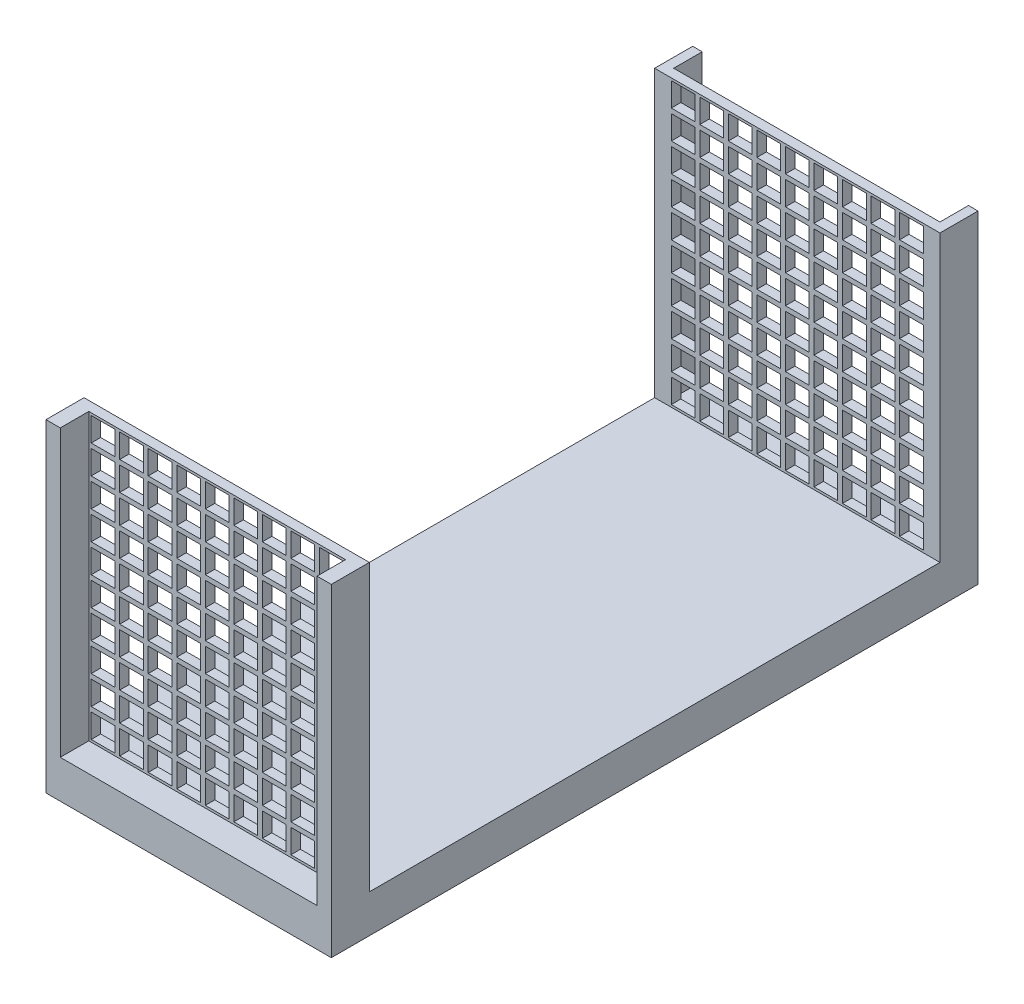
from build123d import *

# Parameters (mm, degrees)
SKETCH1_W            = 15
SKETCH1_H            = 17
BOSS_EXTRUDE1_DEPTH  = 34
CUT_EXTRUDE1_REACH   = 17
SKETCH2_W            = 30
SKETCH2_H            = 15
SKETCH3_W            = 13.5
SKETCH3_H            = 15
CUT_EXTRUDE2_DEPTH   = 1.5
SKETCH4_W            = 1.25
SKETCH4_H            = 1.25
CUT_EXTRUDE3_DEPTH   = 33.5
LPATTERN1_COUNT      = 9
LPATTERN1_PITCH      = 1.5
LPATTERN1_COUNT_DIR2 = 10
LPATTERN1_PITCH_DIR2 = 1.5
SKETCH5_W            = 14
SKETCH5_H            = 15
CUT_EXTRUDE4_DEPTH   = 1.5


with BuildPart() as part:
    # Sketch1 → Boss-Extrude1 (new body)
    with BuildSketch(Plane.XY):
        Rectangle(SKETCH1_W, SKETCH1_H)
    extrude(amount=BOSS_EXTRUDE1_DEPTH)

    # Sketch2 → Cut-Extrude1 (cut, up to next)
    with BuildSketch(Plane(origin=(7.5, 0, 0), x_dir=(0, 0, -1), z_dir=(1, 0, 0)), mode=Mode.PRIVATE) as cut_extrude1_sk1:
        with Locations((-17, 1)):
            Rectangle(SKETCH2_W, SKETCH2_H)
    cut_extrude1_tool1 = extrude(cut_extrude1_sk1.sketch, amount=-CUT_EXTRUDE1_REACH, mode=Mode.PRIVATE) & part.part
    add(cut_extrude1_tool1.solids().sort_by_distance((7.5, 1, 17))[0], mode=Mode.SUBTRACT)

    # Sketch3 → Cut-Extrude2 (cut)
    with BuildSketch(Plane.XY.offset(34)):
        with Locations((0, 1)):
            Rectangle(SKETCH3_W, SKETCH3_H)
    extrude(amount=-CUT_EXTRUDE2_DEPTH, mode=Mode.SUBTRACT)

    # Sketch4 → Cut-Extrude3 (cut, through all)
    with BuildSketch(Plane.XY.offset(32.5)):
        with Locations((-6, 7.75)):
            Rectangle(SKETCH4_W, SKETCH4_H)
    cut_extrude3 = extrude(amount=-CUT_EXTRUDE3_DEPTH, mode=Mode.SUBTRACT)

    # LPattern1: Cut-Extrude3 9 × 10
    with Locations(*[(i * LPATTERN1_PITCH, -j * LPATTERN1_PITCH_DIR2, 0) for i in range(LPATTERN1_COUNT) for j in range(LPATTERN1_COUNT_DIR2) if (i, j) != (0, 0)]):
        add(cut_extrude3, mode=Mode.SUBTRACT)

    # Sketch5 → Cut-Extrude4 (cut)
    with BuildSketch(Plane(origin=(0, 0, 0), x_dir=(-1, 0, 0), z_dir=(0, 0, -1))):
        with Locations((0, 1)):
            Rectangle(SKETCH5_W, SKETCH5_H)
    extrude(amount=-CUT_EXTRUDE4_DEPTH, mode=Mode.SUBTRACT)


solid = part.part
